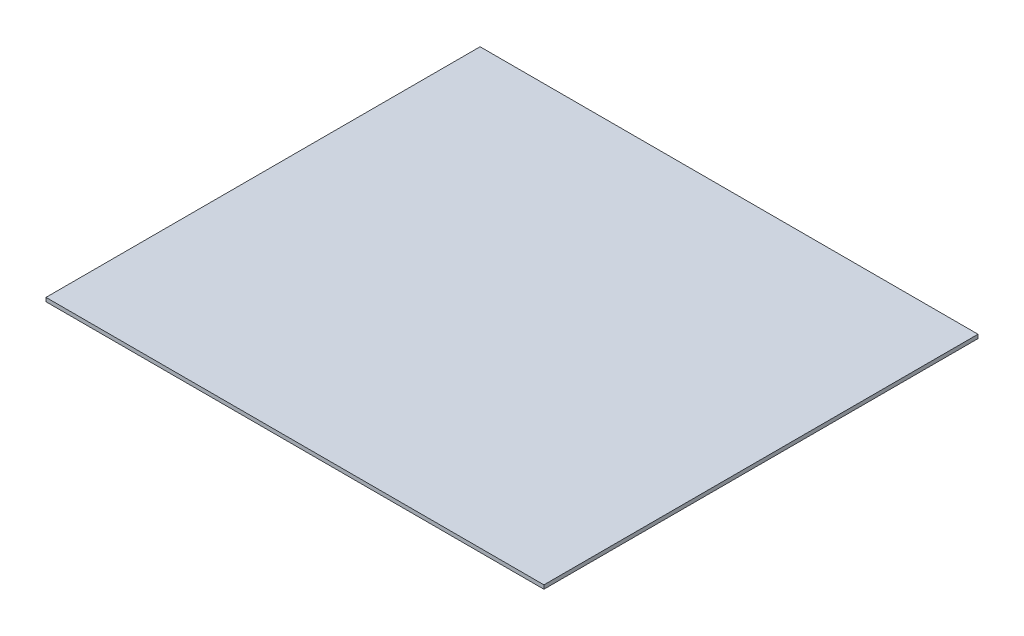
from build123d import *

# Parameters (mm, degrees)
ESQUISSE1_W        = 390
ESQUISSE1_H        = 340
BOSS_EXTRU_1_DEPTH = 3


with BuildPart() as part:
    # Esquisse1 → Boss.-Extru.1 (new body)
    with BuildSketch(Plane(origin=(0, 0, 0), x_dir=(1, 0, 0), z_dir=(0, 1, 0))):
        with Locations((195, -170)):
            Rectangle(ESQUISSE1_W, ESQUISSE1_H)
    extrude(amount=BOSS_EXTRU_1_DEPTH)


solid = part.part
